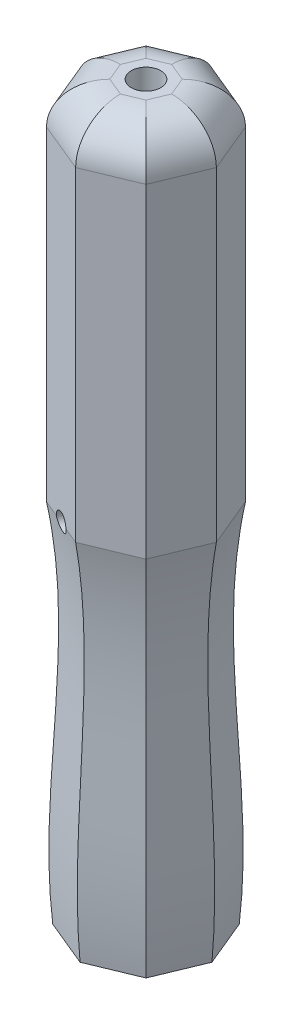
from build123d import *

# Parameters (mm, degrees)
EXTRUDE_1_DEPTH          = 123.83
CUT_EXTRUDE_1_DEPTH      = 10
PATTERN_CIRCULAR_4_COUNT = 8
SKETCH_5_R               = 7.9375
SKETCH_5_R_2             = 2.5
EXTRUDE_2_DEPTH          = 10
FILLET_1_R               = 7
SKETCH_7_R               = 1.5
CUT_EXTRUDE_3_DEPTH      = 40


with BuildPart() as part:
    # Sketch 1 → Extrude 1 (new body)
    with BuildSketch(Plane(origin=(0, 0, 0), x_dir=(1, 0, 0), z_dir=(0, 1, 0))):
        with BuildLine():
            Line((0, -11.906314203), (0, -7.9375))
            ThreePointArc((0, -7.9375), (3.037549744, -7.333293789), (5.612660076, -5.612660076))
            Line((5.612660076, -5.612660076), (8.419035512, -8.419035512))
            Line((8.419035512, -8.419035512), (0, -11.906314203))
        make_face()
    extrude_1 = extrude(amount=EXTRUDE_1_DEPTH)

    # Sketch 4 → Cut-Extrude 1 (cut, symmetric)
    with BuildSketch(Plane(origin=(0, 0, 0), x_dir=(0, 1, 0), z_dir=(0.923879533, 0, -0.382683432))):
        with BuildLine():
            Line((0, 13.154938161), (61.915, 13.154938161))
            Line((61.915, 13.154938161), (61.915, 11))
            add(Edge.make_bspline(
                [(61.915, 11), (41.306817411, 7.531903846), (20.665469899, 12.083633252), (0, 10.31)],
                knots=[0, 0, 0, 0, 1, 1, 1, 1], degree=3))
            Line((0, 10.31), (0, 13.154938161))
        make_face()
    cut_extrude_1 = extrude(amount=CUT_EXTRUDE_1_DEPTH, both=True, mode=Mode.SUBTRACT)

    # Pattern Circular 4: Extrude 1, Cut-Extrude 1 ×8 about axis
    pattern_circular_4_axis = Axis((0, 0, 0), (0, -1, 0))
    for i in range(1, PATTERN_CIRCULAR_4_COUNT):
        add(extrude_1.rotate(pattern_circular_4_axis, i * 360 / PATTERN_CIRCULAR_4_COUNT))
        add(cut_extrude_1.rotate(pattern_circular_4_axis, i * 360 / PATTERN_CIRCULAR_4_COUNT), mode=Mode.SUBTRACT)

    # Sketch 5 → Extrude 2 (add)
    with BuildSketch(Plane(origin=(0, 123.83, 0), x_dir=(1, 0, 0), z_dir=(0, 1, 0))):
        Circle(SKETCH_5_R)
        Circle(SKETCH_5_R_2, mode=Mode.SUBTRACT)
    extrude(amount=-EXTRUDE_2_DEPTH)

    # Fillet 1
    fillet_1_edges = [part.edges().sort_by_distance(p)[0] for p in [
        (10.162674858, 123.83, 4.209517756),
        (10.162674858, 123.83, -4.209517756),
        (4.209517756, 123.83, -10.162674858),
        (-4.209517756, 123.83, -10.162674858),
        (-10.162674858, 123.83, -4.209517756),
        (-10.162674858, 123.83, 4.209517756),
        (-4.209517756, 123.83, 10.162674858),
        (4.209517756, 123.83, 10.162674858),
    ]]
    fillet(fillet_1_edges, radius=FILLET_1_R)

    # Sketch 7 → Cut-Extrude 3 (cut)
    with BuildSketch(Plane(origin=(-4.209517756, 0, 10.162674858), x_dir=(0.923879533, 0, 0.382683432), z_dir=(-0.382683432, 0, 0.923879533))):
        with Locations((0, 61.915)):
            Circle(SKETCH_7_R)
    extrude(amount=-CUT_EXTRUDE_3_DEPTH, mode=Mode.SUBTRACT)


solid = part.part
